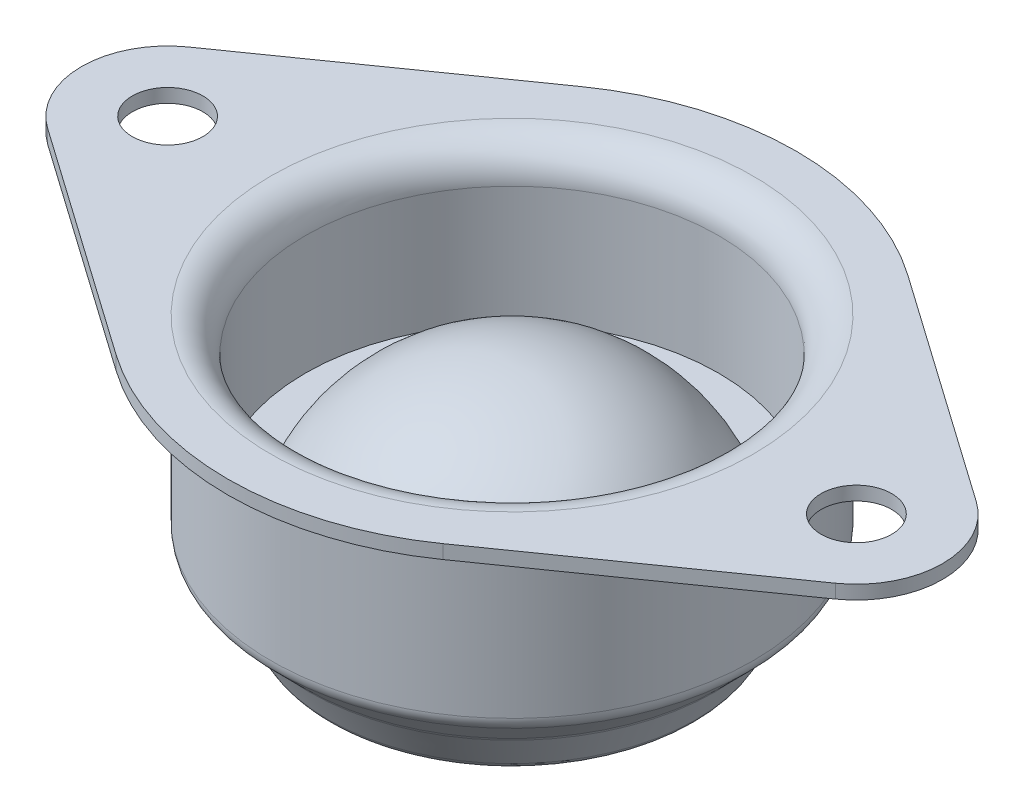
from build123d import *

# Parameters (mm, degrees)
FILLET1_R                      = 1
FILLET2_R                      = 2
CUT_EXTRUDE1_REACH             = 23
F_4_1_4_1_DIAMETER_HOLE1_D     = 4.1
F_4_1_4_1_DIAMETER_HOLE1_DEPTH = 0.8


with BuildPart() as part:
    # Sketch1 → Revolve1 (revolve)
    with BuildSketch(Plane.XY):
        with BuildLine():
            Line((14, 1.7), (14, -8.3))
            Line((14, -8.3), (11.878679656, -10.421320344))
            Line((11.878679656, -10.421320344), (10.378679656, -13.019396555))
            Line((10.378679656, -13.019396555), (7.223021359, -13.019396555))
            ThreePointArc((7.223021359, -13.019396555), (4.533460369, -16.974758328), (0, -18.5))
            Line((0, -18.5), (0, 0))
            ThreePointArc((0, 0), (5.941029682, -1.742345528), (10, -6.417424305))
            Line((10, -6.417424305), (12, -6.417424305))
            Line((12, -6.417424305), (12, 2.5))
            Line((12, 2.5), (25, 2.5))
            Line((25, 2.5), (25, 1.7))
            Line((25, 1.7), (14, 1.7))
        make_face()
    revolve(axis=Axis((0, 43.298682787, 0), (0, -1, 0)))

    # Fillet1
    fillet1_edges = [part.edges().sort_by_distance(p)[0] for p in [
        (-7.223021359, -13.019396555, 0),
        (-10.378679656, -13.019396555, 0),
        (-11.878679656, -10.421320344, 0),
        (-14, -8.3, 0),
        (-14, 1.7, 0),
    ]]
    fillet(fillet1_edges, radius=FILLET1_R)

    # Fillet2
    fillet2_edges = [part.edges().sort_by_distance(p)[0] for p in [
        (-12, 2.5, 0),
    ]]
    fillet(fillet2_edges, radius=FILLET2_R)

    # Sketch2 → Cut-Extrude1 (cut, up to next)
    with BuildSketch(Plane(origin=(0, 2.5, 0), x_dir=(1, 0, 0), z_dir=(0, 1, 0)), mode=Mode.PRIVATE) as cut_extrude1_sk1:
        with BuildLine():
            ThreePointArc((-25, 0), (-24.437059837, 2.304886114), (-22.875, 4.090767043))
            Line((-22.875, 4.090767043), (-9.4875, 13.499531242))
            ThreePointArc((-9.4875, 13.499531242), (0, 16.5), (9.4875, 13.499531242))
            Line((9.4875, 13.499531242), (22.875, 4.090767043))
            ThreePointArc((22.875, 4.090767043), (24.437059837, 2.304886114), (25, 0))
            ThreePointArc((25, 0), (0, 25), (-25, 0))
        make_face()
    cut_extrude1_tool1 = extrude(cut_extrude1_sk1.sketch, amount=-CUT_EXTRUDE1_REACH, mode=Mode.PRIVATE) & part.part
    add(cut_extrude1_tool1.solids().sort_by_distance((-24.486668, 2.5, -2.330656))[0], mode=Mode.SUBTRACT)
    # Sketch2 → Cut-Extrude1 (cut, up to next)
    with BuildSketch(Plane(origin=(0, 2.5, 0), x_dir=(1, 0, 0), z_dir=(0, 1, 0)), mode=Mode.PRIVATE) as cut_extrude1_sk2:
        with BuildLine():
            ThreePointArc((-22.875, -4.090767043), (-24.437059837, -2.304886114), (-25, 0))
            ThreePointArc((-25, 0), (0, -25), (25, 0))
            ThreePointArc((25, 0), (24.437059837, -2.304886114), (22.875, -4.090767043))
            Line((22.875, -4.090767043), (9.4875, -13.499531242))
            ThreePointArc((9.4875, -13.499531242), (0, -16.5), (-9.4875, -13.499531242))
            Line((-9.4875, -13.499531242), (-22.875, -4.090767043))
        make_face()
    cut_extrude1_tool2 = extrude(cut_extrude1_sk2.sketch, amount=-CUT_EXTRUDE1_REACH, mode=Mode.PRIVATE) & part.part
    add(cut_extrude1_tool2.solids().sort_by_distance((-16.502685, 2.5, 9.252511))[0], mode=Mode.SUBTRACT)

    # Ø4.1 (4.1) Diameter Hole1
    with Locations(Plane(origin=(0, 2.5, 0), x_dir=(1, 0, 0), z_dir=(0, 1, 0))):
        with Locations((20, 0), (-20, 0)):
            Hole(F_4_1_4_1_DIAMETER_HOLE1_D / 2, depth=F_4_1_4_1_DIAMETER_HOLE1_DEPTH)


solid = part.part
